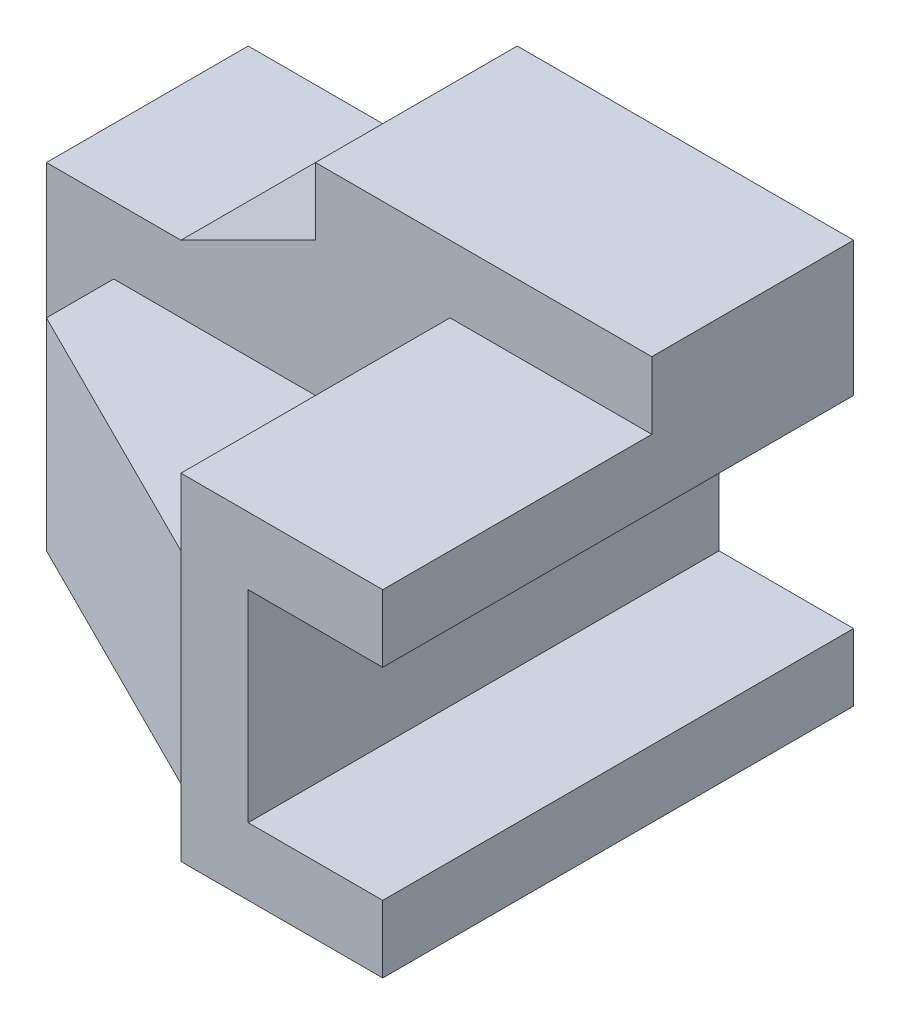
from build123d import *

# Parameters (mm, degrees)
BOSS_EXTRUDE1_DEPTH = 30
BOSS_EXTRUDE2_DEPTH = 30
SKETCH5_W           = 20
SKETCH5_H           = 30
CUT_EXTRUDE1_DEPTH  = 71
SKETCH6_W           = 30
SKETCH6_H           = 10
CUT_EXTRUDE2_DEPTH  = 40
CUT_EXTRUDE3_DEPTH  = 71


with BuildPart() as part:
    # Sketch1 → Boss-Extrude1 (new body)
    with BuildSketch(Plane(origin=(0, 0, 0), x_dir=(1, 0, 0), z_dir=(0, 1, 0))):
        Polygon((0, 0), (90, 0), (90, -70), (60, -70), (60, -60), (50, -60), (10, -40), (10, -30), (0, -30), align=None)
    extrude(amount=BOSS_EXTRUDE1_DEPTH)

    # Sketch3 → Boss-Extrude2 (add)
    with BuildSketch(Plane(origin=(0, 30, 0), x_dir=(1, 0, 0), z_dir=(0, 1, 0))):
        Polygon((0, 0), (90, 0), (90, -70), (60, -70), (60, -30), (0, -30), align=None)
    extrude(amount=BOSS_EXTRUDE2_DEPTH)

    # Sketch5 → Cut-Extrude1 (cut, through all)
    with BuildSketch(Plane.XY.offset(70)):
        with Locations((80, 25)):
            Rectangle(SKETCH5_W, SKETCH5_H)
    extrude(amount=-CUT_EXTRUDE1_DEPTH, mode=Mode.SUBTRACT)

    # Sketch6 → Cut-Extrude2 (cut)
    with BuildSketch(Plane.XY.offset(70)):
        with Locations((75, 55)):
            Rectangle(SKETCH6_W, SKETCH6_H)
    extrude(amount=-CUT_EXTRUDE2_DEPTH, mode=Mode.SUBTRACT)

    # Sketch7 → Cut-Extrude3 (cut, through all)
    with BuildSketch(Plane(origin=(0, 0, 0), x_dir=(-1, 0, 0), z_dir=(0, 0, -1))):
        Polygon((-40, 60), (-40, 50), (-20, 40), (0, 40), (0, 60), align=None)
    extrude(amount=-CUT_EXTRUDE3_DEPTH, mode=Mode.SUBTRACT)


solid = part.part
